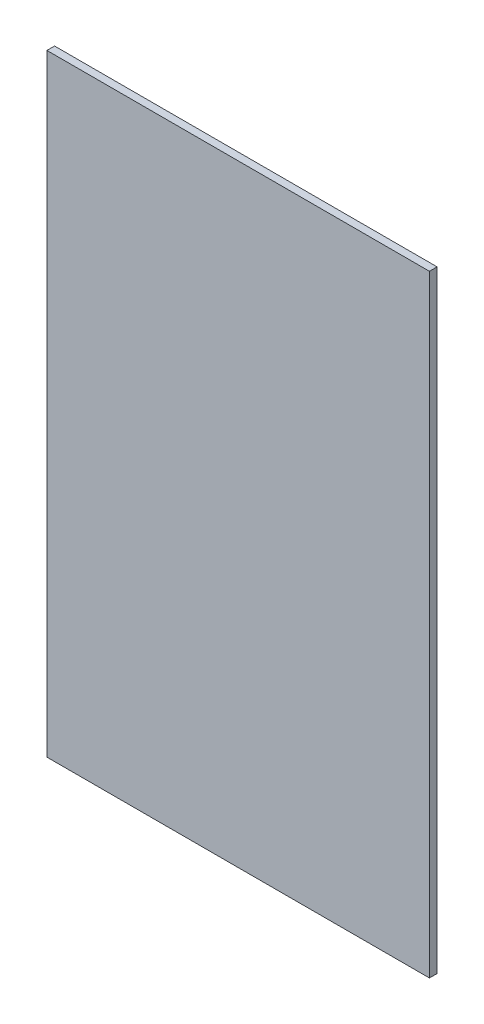
from build123d import *

# Parameters (mm, degrees)
CROQUIS1_W              = 250
CROQUIS1_H              = 400
SALIENTE_EXTRUIR1_DEPTH = 5


with BuildPart() as part:
    # Croquis1 → Saliente-Extruir1 (new body)
    with BuildSketch(Plane.XY):
        Rectangle(CROQUIS1_W, CROQUIS1_H)
    extrude(amount=SALIENTE_EXTRUIR1_DEPTH)


solid = part.part
